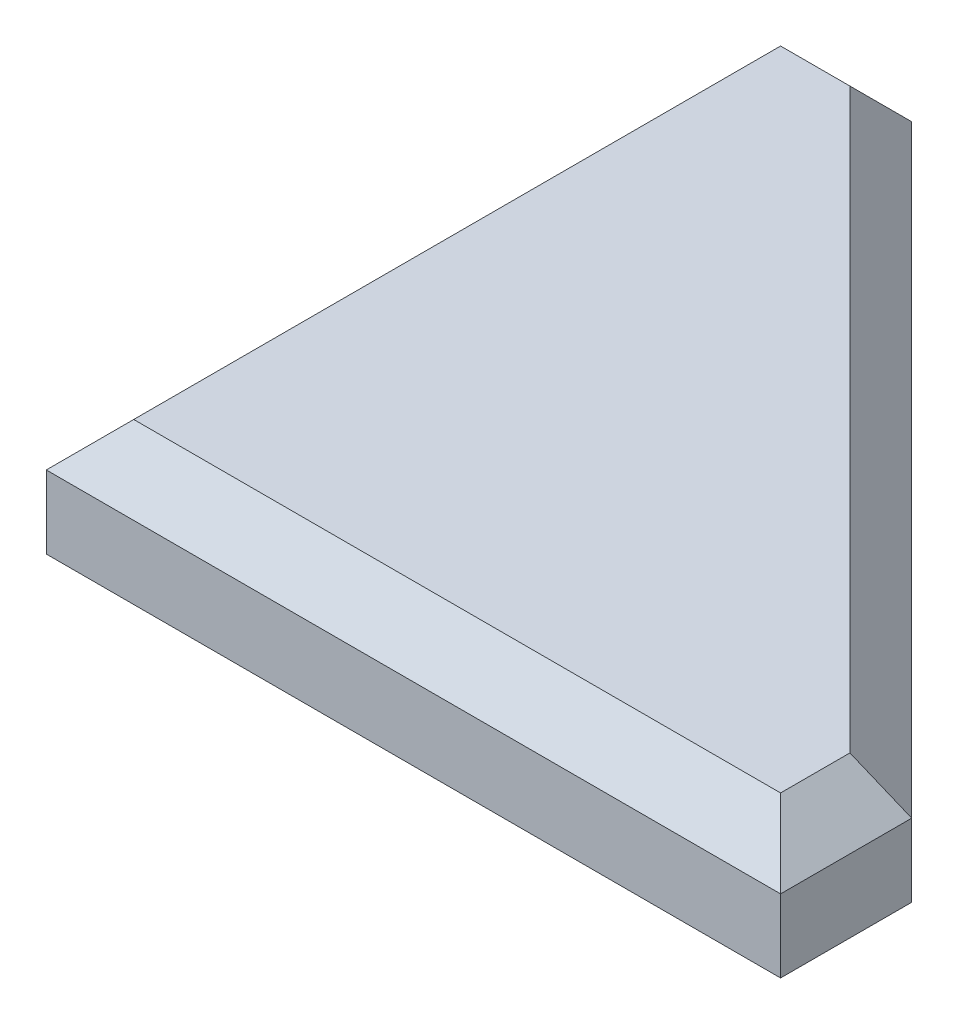
from build123d import *

# Parameters (mm, degrees)
BOSS_EXTRU_1_DEPTH = 8
CHANFREIN1_SIZE    = 3


with BuildPart() as part:
    # Esquisse1 → Boss.-Extru.1 (new body)
    with BuildSketch(Plane(origin=(0, 0, 0), x_dir=(1, 0, 0), z_dir=(0, 1, 0))):
        Polygon((0, 0), (0, 50.39696962), (9, 50.39696962), (50.39696962, 9), (50.39696962, 0), align=None)
    extrude(amount=BOSS_EXTRU_1_DEPTH)

    # Chanfrein1
    chanfrein1_edges = [part.edges().sort_by_distance(p)[0] for p in [
        (29.69848481, 8, -29.69848481),
        (4.5, 8, -50.39696962),
        (0, 8, -25.19848481),
        (25.19848481, 8, 0),
        (50.39696962, 8, -4.5),
    ]]
    chamfer(chanfrein1_edges, length=CHANFREIN1_SIZE)


solid = part.part
